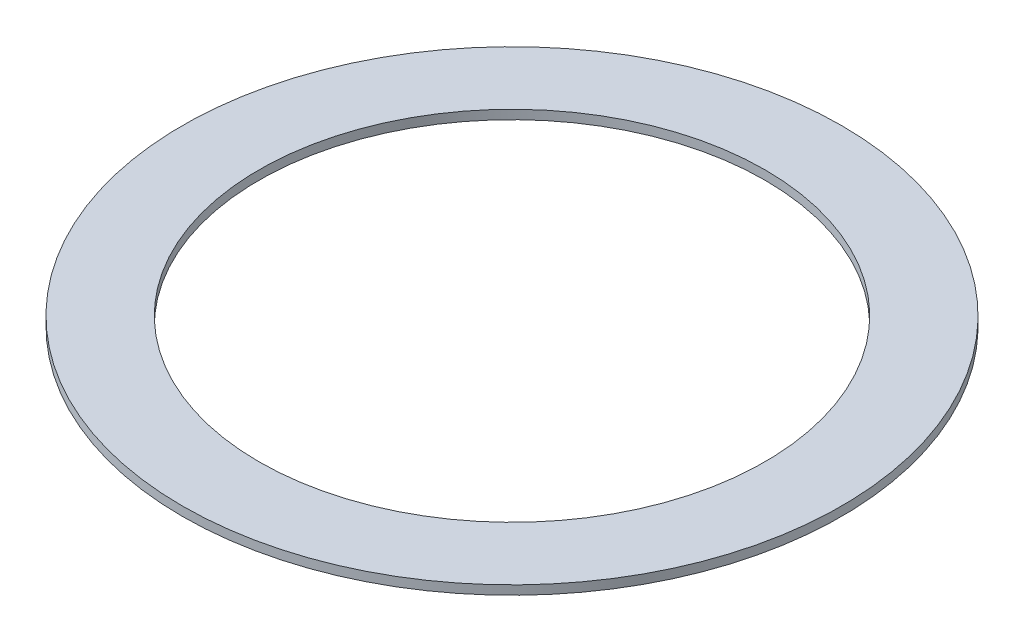
from build123d import *

# Parameters (mm, degrees)
SKETCH1_R           = 115.824
SKETCH1_R_2         = 88.9
BOSS_EXTRUDE1_DEPTH = 3.175


with BuildPart() as part:
    # Sketch1 → Boss-Extrude1 (new body)
    with BuildSketch(Plane(origin=(0, 0, 0), x_dir=(1, 0, 0), z_dir=(0, 1, 0))):
        Circle(SKETCH1_R)
        Circle(SKETCH1_R_2, mode=Mode.SUBTRACT)
    extrude(amount=BOSS_EXTRUDE1_DEPTH)


solid = part.part
